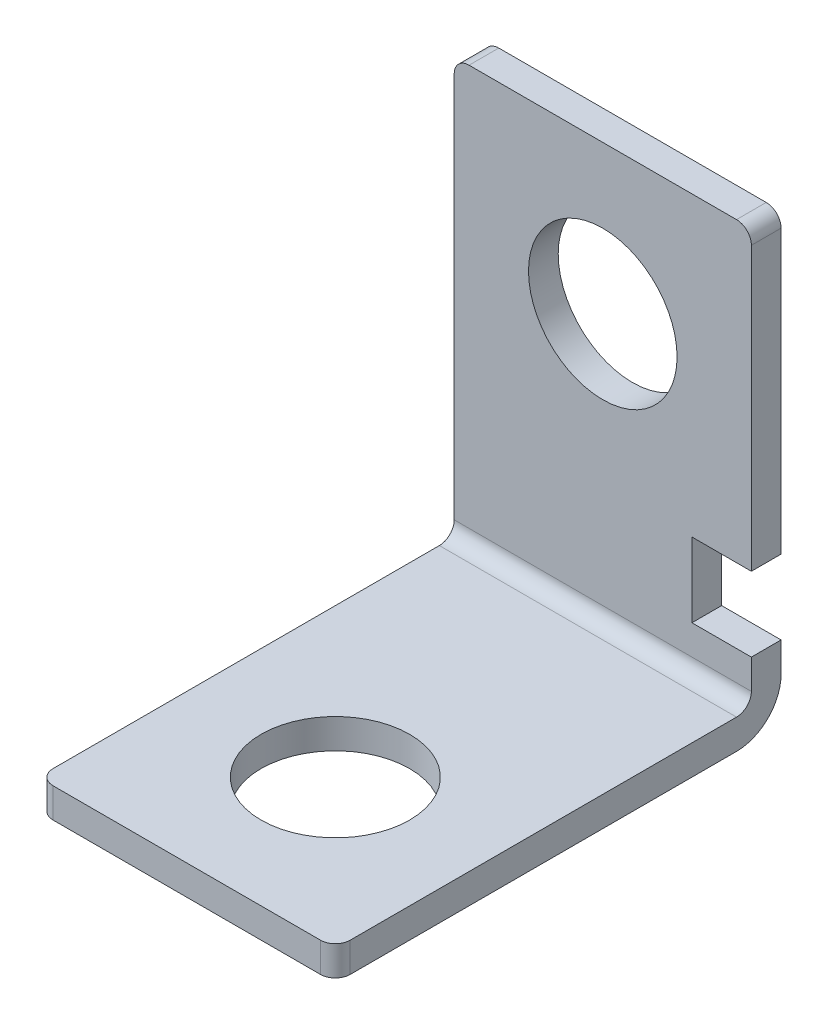
from build123d import *

# Parameters (mm, degrees)
EXTRUDE_THIN1_DEPTH = 10
SKETCH2_W           = 4
SKETCH2_H           = 5
CUT_EXTRUDE1_DEPTH  = 10
FILLET1_R           = 3
FILLET2_R           = 1
SKETCH3_R           = 5
CUT_EXTRUDE2_DEPTH  = 10
SKETCH4_R           = 5
CUT_EXTRUDE3_DEPTH  = 10
FILLET3_R           = 1


with BuildPart() as part:
    # Sketch1 → Extrude-Thin1 (new body, symmetric)
    with BuildSketch(Plane(origin=(0, 0, 0), x_dir=(0, 0, -1), z_dir=(1, 0, 0))):
        Polygon((-30, 0), (0, 0), (0, 30), (-2, 30), (-2, 2), (-30, 2), align=None)
    extrude(amount=EXTRUDE_THIN1_DEPTH, both=True)

    # Sketch2 → Cut-Extrude1 (cut)
    with BuildSketch(Plane.XY.offset(2)):
        with Locations((8, 7.5)):
            Rectangle(SKETCH2_W, SKETCH2_H)
    extrude(amount=-CUT_EXTRUDE1_DEPTH, mode=Mode.SUBTRACT)

    # Fillet1
    fillet1_edges = [part.edges().sort_by_distance(p)[0] for p in [
        (0, 0, 0),
    ]]
    fillet(fillet1_edges, radius=FILLET1_R)

    # Fillet2
    fillet2_edges = [part.edges().sort_by_distance(p)[0] for p in [
        (0, 2, 2),
    ]]
    fillet(fillet2_edges, radius=FILLET2_R)

    # Sketch3 → Cut-Extrude2 (cut)
    with BuildSketch(Plane.XY.offset(2)):
        with Locations((0, 20)):
            Circle(SKETCH3_R)
    extrude(amount=-CUT_EXTRUDE2_DEPTH, mode=Mode.SUBTRACT)

    # Sketch4 → Cut-Extrude3 (cut)
    with BuildSketch(Plane(origin=(0, 2, 0), x_dir=(1, 0, 0), z_dir=(0, 1, 0))):
        with Locations((0, -20)):
            Circle(SKETCH4_R)
    extrude(amount=-CUT_EXTRUDE3_DEPTH, mode=Mode.SUBTRACT)

    # Fillet3
    fillet3_edges = [part.edges().sort_by_distance(p)[0] for p in [
        (10, 1, 30),
        (-10, 1, 30),
        (-10, 30, 1),
        (10, 30, 1),
    ]]
    fillet(fillet3_edges, radius=FILLET3_R)


solid = part.part
